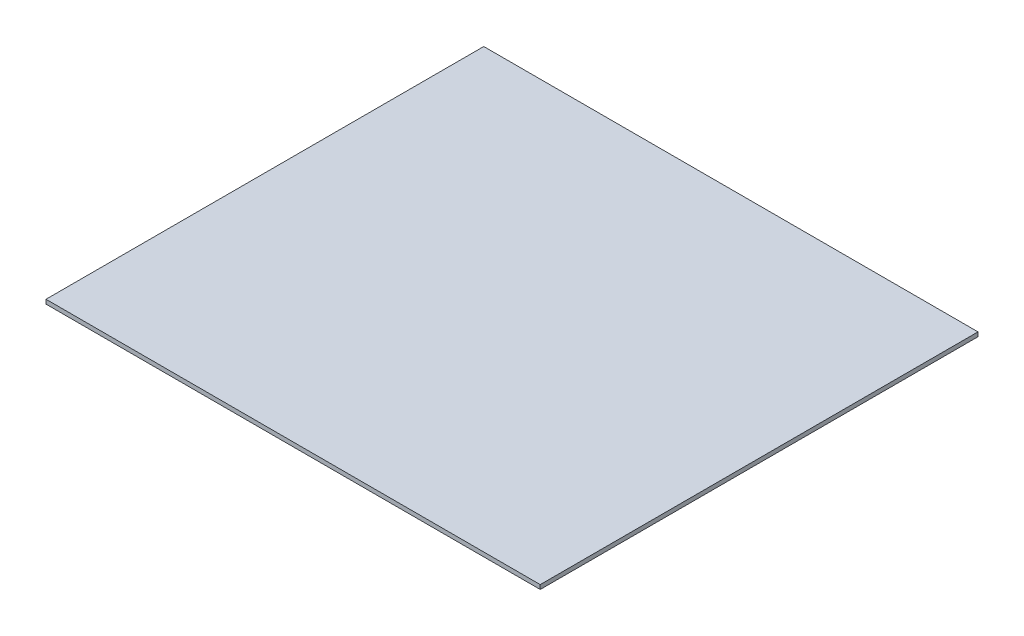
from build123d import *

# Parameters (mm, degrees)
SKETCH1_W           = 350
SKETCH1_H           = 310
BOSS_EXTRUDE1_DEPTH = 3


with BuildPart() as part:
    # Sketch1 → Boss-Extrude1 (new body)
    with BuildSketch(Plane(origin=(0, 0, 0), x_dir=(1, 0, 0), z_dir=(0, 1, 0))):
        Rectangle(SKETCH1_W, SKETCH1_H)
    extrude(amount=BOSS_EXTRUDE1_DEPTH)


solid = part.part
